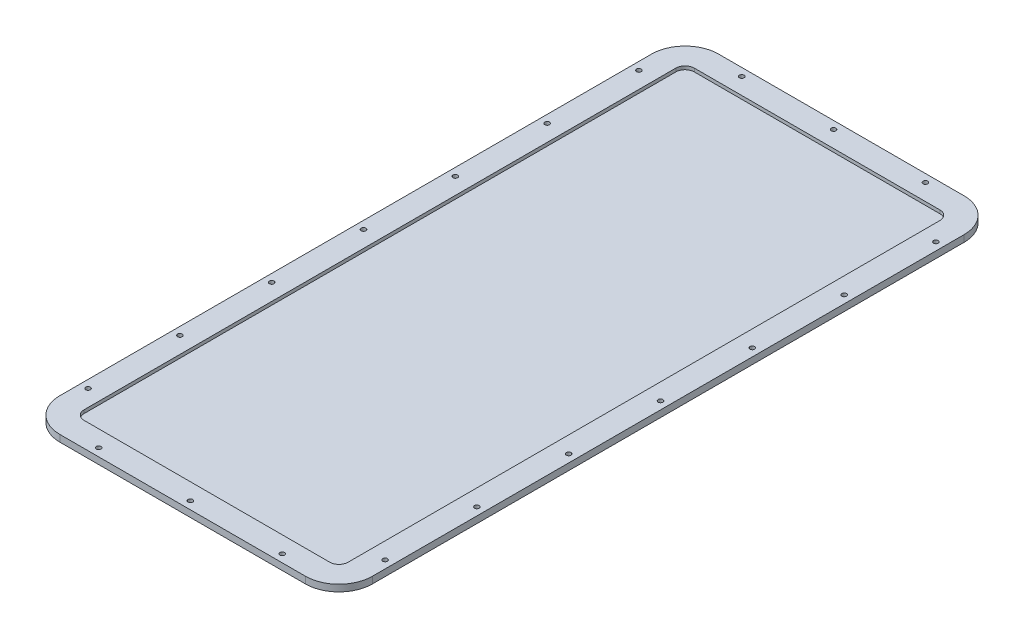
from build123d import *

# Parameters (mm, degrees)
SKETCH1_R           = 2.1
BOSS_EXTRUDE1_DEPTH = 6
CUT_EXTRUDE1_DEPTH  = 3
SKETCH4_R           = 4.125
CUT_EXTRUDE2_DEPTH  = 2.5


with BuildPart() as part:
    # Sketch1 → Boss-Extrude1 (new body)
    with BuildSketch(Plane(origin=(0, 0, 0), x_dir=(-1, 0, 0), z_dir=(0, 1, 0))):
        with BuildLine():
            Line((90.927407972, 302.93116582), (-129.072592028, 302.93116582))
            ThreePointArc((-129.072592028, 302.93116582), (-150.285795463, 294.144369255), (-159.072592028, 272.93116582))
            Line((-159.072592028, 272.93116582), (-159.072592028, -257.06883418))
            ThreePointArc((-159.072592028, -257.06883418), (-150.285795463, -278.282037616), (-129.072592028, -287.06883418))
            Line((-129.072592028, -287.06883418), (90.927407972, -287.06883418))
            ThreePointArc((90.927407972, -287.06883418), (112.140611408, -278.282037616), (120.927407972, -257.06883418))
            Line((120.927407972, -257.06883418), (120.927407972, 272.93116582))
            ThreePointArc((120.927407972, 272.93116582), (112.140611408, 294.144369255), (90.927407972, 302.93116582))
        make_face()
        with Locations((-152.072592028, 254.608155129)):
            Circle(SKETCH1_R, mode=Mode.SUBTRACT)
        with Locations((-101.298255131, 295.93116582)):
            Circle(SKETCH1_R, mode=Mode.SUBTRACT)
        with Locations((-19.072592028, 295.93116582)):
            Circle(SKETCH1_R, mode=Mode.SUBTRACT)
        with Locations((63.153071075, 295.93116582)):
            Circle(SKETCH1_R, mode=Mode.SUBTRACT)
        with Locations((113.927407972, 254.608155129)):
            Circle(SKETCH1_R, mode=Mode.SUBTRACT)
        with Locations((-152.072592028, 7.93116582)):
            Circle(SKETCH1_R, mode=Mode.SUBTRACT)
        with Locations((-152.072592028, -74.294497284)):
            Circle(SKETCH1_R, mode=Mode.SUBTRACT)
        with Locations((-152.072592028, -156.520160387)):
            Circle(SKETCH1_R, mode=Mode.SUBTRACT)
        with Locations((-152.072592028, -238.74582349)):
            Circle(SKETCH1_R, mode=Mode.SUBTRACT)
        with Locations((-101.298255131, -280.06883418)):
            Circle(SKETCH1_R, mode=Mode.SUBTRACT)
        with Locations((-19.072592028, -280.06883418)):
            Circle(SKETCH1_R, mode=Mode.SUBTRACT)
        with Locations((63.153071075, -280.06883418)):
            Circle(SKETCH1_R, mode=Mode.SUBTRACT)
        with Locations((113.927407972, -238.74582349)):
            Circle(SKETCH1_R, mode=Mode.SUBTRACT)
        with Locations((113.927407972, -156.520160387)):
            Circle(SKETCH1_R, mode=Mode.SUBTRACT)
        with Locations((113.927407972, -74.294497284)):
            Circle(SKETCH1_R, mode=Mode.SUBTRACT)
        with Locations((113.927407972, 7.93116582)):
            Circle(SKETCH1_R, mode=Mode.SUBTRACT)
        with Locations((-152.072592028, 90.156828923)):
            Circle(SKETCH1_R, mode=Mode.SUBTRACT)
        with Locations((-152.072592028, 172.382492026)):
            Circle(SKETCH1_R, mode=Mode.SUBTRACT)
        with Locations((113.927407972, 90.156828923)):
            Circle(SKETCH1_R, mode=Mode.SUBTRACT)
        with Locations((113.927407972, 172.382492026)):
            Circle(SKETCH1_R, mode=Mode.SUBTRACT)
    extrude(amount=BOSS_EXTRUDE1_DEPTH)

    # Sketch3 → Cut-Extrude1 (cut)
    with BuildSketch(Plane(origin=(0, 6, 0), x_dir=(1, 0, 0), z_dir=(0, 1, 0))):
        with BuildLine():
            Line((129.072592028, -281.18116582), (-90.927407972, -281.18116582))
            ThreePointArc((-90.927407972, -281.18116582), (-96.761038917, -278.764796764), (-99.177407972, -272.93116582))
            Line((-99.177407972, -272.93116582), (-99.177407972, 257.06883418))
            ThreePointArc((-99.177407972, 257.06883418), (-96.761038917, 262.902465125), (-90.927407972, 265.31883418))
            Line((-90.927407972, 265.31883418), (129.072592028, 265.31883418))
            ThreePointArc((129.072592028, 265.31883418), (134.906222973, 262.902465125), (137.322592028, 257.06883418))
            Line((137.322592028, 257.06883418), (137.322592028, -272.93116582))
            ThreePointArc((137.322592028, -272.93116582), (134.906222973, -278.764796764), (129.072592028, -281.18116582))
        make_face()
    extrude(amount=-CUT_EXTRUDE1_DEPTH, mode=Mode.SUBTRACT)

    # Sketch4 → Cut-Extrude2 (cut)
    with BuildSketch(Plane.XZ):
        with Locations((101.298255131, -280.06883418)):
            Circle(SKETCH4_R)
        with Locations((152.072592028, -238.74582349)):
            Circle(SKETCH4_R)
        with Locations((19.072592028, -280.06883418)):
            Circle(SKETCH4_R)
        with Locations((-63.153071075, -280.06883418)):
            Circle(SKETCH4_R)
        with Locations((-113.927407972, -238.74582349)):
            Circle(SKETCH4_R)
        with Locations((-113.927407972, -156.520160387)):
            Circle(SKETCH4_R)
        with Locations((-113.927407972, -74.294497284)):
            Circle(SKETCH4_R)
        with Locations((-113.927407972, 7.93116582)):
            Circle(SKETCH4_R)
        with Locations((-113.927407972, 90.156828923)):
            Circle(SKETCH4_R)
        with Locations((-113.927407972, 172.382492026)):
            Circle(SKETCH4_R)
        with Locations((-113.927407972, 254.608155129)):
            Circle(SKETCH4_R)
        with Locations((-63.153071075, 295.93116582)):
            Circle(SKETCH4_R)
        with Locations((19.072592028, 295.93116582)):
            Circle(SKETCH4_R)
        with Locations((101.298255131, 295.93116582)):
            Circle(SKETCH4_R)
        with Locations((152.072592028, 254.608155129)):
            Circle(SKETCH4_R)
        with Locations((152.072592028, 172.382492026)):
            Circle(SKETCH4_R)
        with Locations((152.072592028, 90.156828923)):
            Circle(SKETCH4_R)
        with Locations((152.072592028, 7.93116582)):
            Circle(SKETCH4_R)
        with Locations((152.072592028, -74.294497284)):
            Circle(SKETCH4_R)
        with Locations((152.072592028, -156.520160387)):
            Circle(SKETCH4_R)
    extrude(amount=-CUT_EXTRUDE2_DEPTH, mode=Mode.SUBTRACT)


solid = part.part
